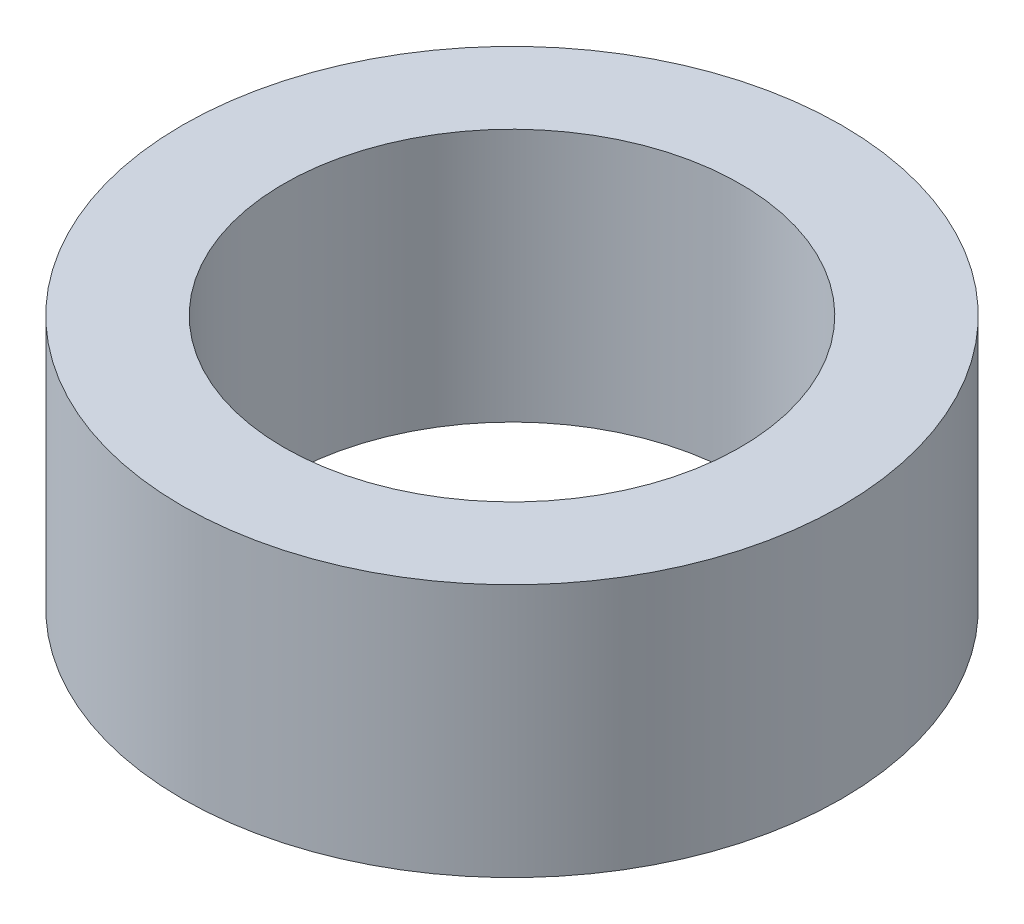
from build123d import *

# Parameters (mm, degrees)
SKETCH1_R           = 2.6
SKETCH1_R_2         = 1.8
BOSS_EXTRUDE1_DEPTH = 2


with BuildPart() as part:
    # Sketch1 → Boss-Extrude1 (new body)
    with BuildSketch(Plane(origin=(0, 0, 0), x_dir=(1, 0, 0), z_dir=(0, 1, 0))):
        Circle(SKETCH1_R)
        Circle(SKETCH1_R_2, mode=Mode.SUBTRACT)
    extrude(amount=BOSS_EXTRUDE1_DEPTH)


solid = part.part
